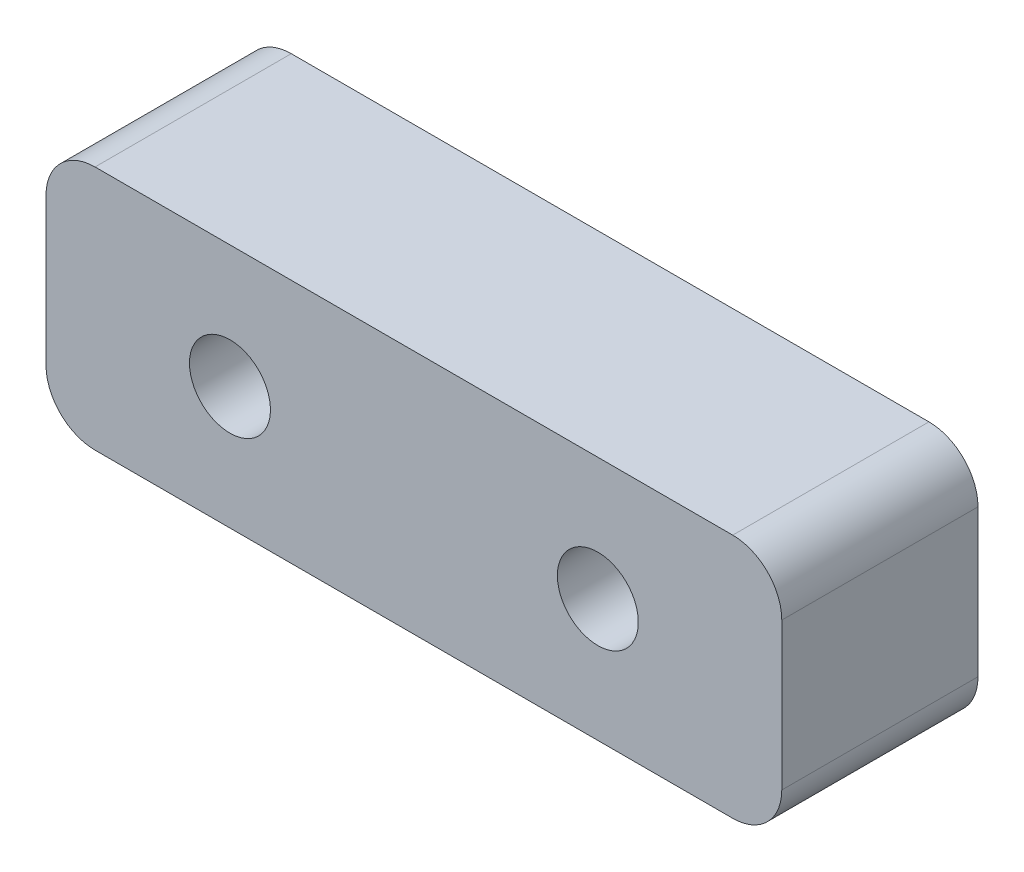
from build123d import *

# Parameters (mm, degrees)
SKETCH_1_W          = 30
SKETCH_1_H          = 10
EXTRUDE_1_DEPTH     = 8
FILLET_1_R          = 2
SKETCH_3_R          = 1.65
CUT_EXTRUDE_1_DEPTH = 9


with BuildPart() as part:
    # 草图1 → 凸台-拉伸1 (new body)
    with BuildSketch(Plane.XY):
        Rectangle(SKETCH_1_W, SKETCH_1_H)
    extrude(amount=EXTRUDE_1_DEPTH)

    # 圆角1
    fillet_1_edges = [part.edges().sort_by_distance(p)[0] for p in [
        (15, -5, 4),
        (-15, -5, 4),
        (-15, 5, 4),
        (15, 5, 4),
    ]]
    fillet(fillet_1_edges, radius=FILLET_1_R)

    # 草图3 → 切除-拉伸1 (cut, through all)
    with BuildSketch(Plane(origin=(0, 0, 0), x_dir=(-1, 0, 0), z_dir=(0, 0, -1))):
        with Locations((-7.5, 0)):
            Circle(SKETCH_3_R)
        with Locations((7.5, 0)):
            Circle(SKETCH_3_R)
    extrude(amount=-CUT_EXTRUDE_1_DEPTH, mode=Mode.SUBTRACT)


solid = part.part
